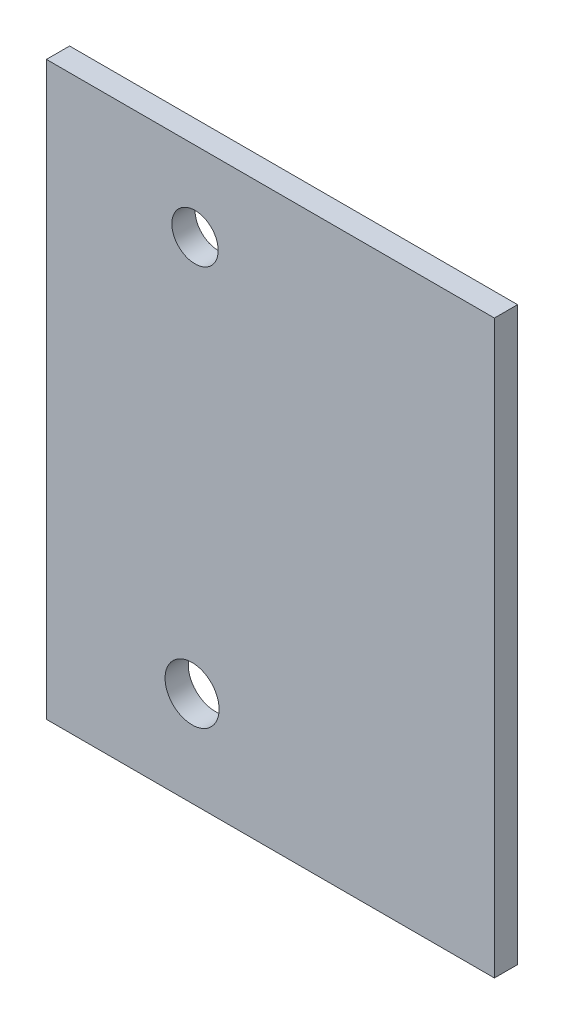
from build123d import *

# Parameters (mm, degrees)
SKETCH_1_W          = 29
SKETCH_1_H          = 37
EXTRUDE_1_DEPTH     = 1.5
SKETCH_2_R          = 1.5
SKETCH_2_R_2        = 1.75
CUT_EXTRUDE_1_DEPTH = 2.5


with BuildPart() as part:
    # Эскиз1 → Бобышка-Вытянуть1 (new body)
    with BuildSketch(Plane.XY):
        with Locations((14.5, 18.5)):
            Rectangle(SKETCH_1_W, SKETCH_1_H)
    extrude(amount=EXTRUDE_1_DEPTH)

    # Эскиз2 → Вырез-Вытянуть1 (cut, through all)
    with BuildSketch(Plane.XY.offset(1.5)):
        with Locations((9.62, 31.845)):
            Circle(SKETCH_2_R)
        with Locations((9.4291, 6.15396)):
            Circle(SKETCH_2_R_2)
    extrude(amount=-CUT_EXTRUDE_1_DEPTH, mode=Mode.SUBTRACT)


solid = part.part
